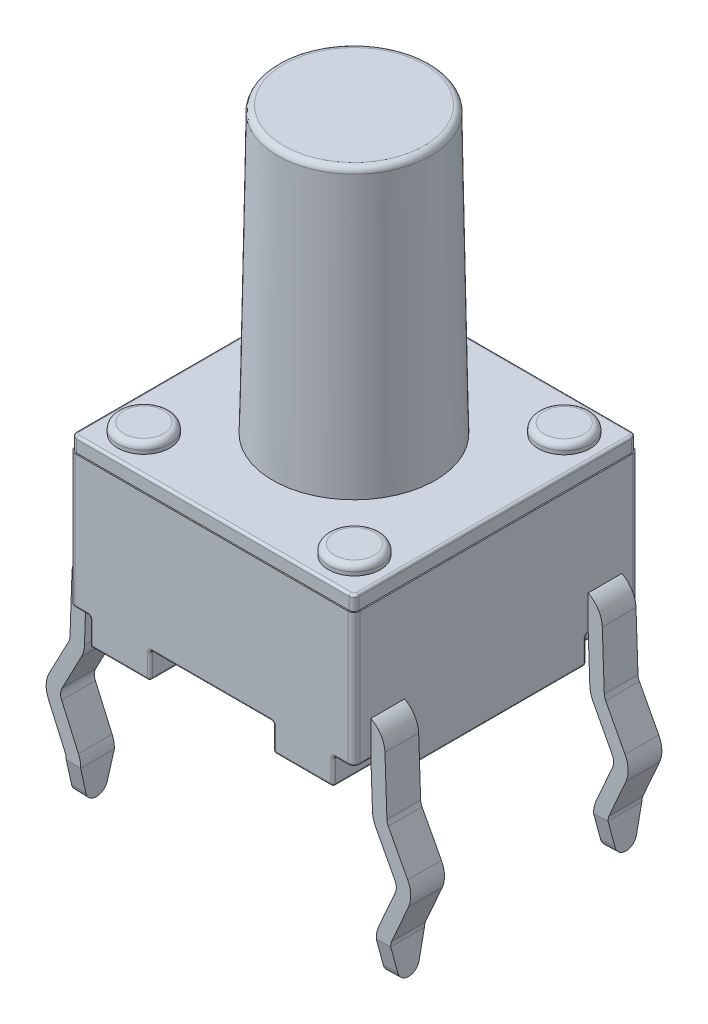
from build123d import *

# Parameters (mm, degrees)
BOSS_EXTRUDE1_START  = 0.5588
SKETCH1_W            = 6.0071
SKETCH1_H            = 6.0071
BOSS_EXTRUDE1_DEPTH  = 2.8194
FILLET1_R            = 0.127
BOSS_EXTRUDE2_DEPTH  = 0.3048
BOSS_EXTRUDE3_REACH  = 7.622
SKETCH4_R            = 0.5461
BOSS_EXTRUDE4_DEPTH  = 0.2032
SKETCH5_R            = 1.7145
BOSS_EXTRUDE5_DEPTH  = 6
BOSS_EXTRUDE5_TAPER  = 1
FILLET2_R            = 0.127
FILLET3_R            = 0.0508
EXTRUDE_THIN1_START  = -0.3556
EXTRUDE_THIN1_DEPTH  = 0.7112
CUT_EXTRUDE1_DEPTH   = 0.7112
MIRROR3_START        = -0.3556
MIRROR3_COPY_1_DEPTH = 0.7112
MIRROR3_COPY_2_DEPTH = 0.7112


with BuildPart() as part:
    # Sketch1 → Boss-Extrude1 (new body)
    with BuildSketch(Plane(origin=(0, 0, 0), x_dir=(1, 0, 0), z_dir=(0, 1, 0)).offset(BOSS_EXTRUDE1_START)):
        Rectangle(SKETCH1_W, SKETCH1_H)
    extrude(amount=BOSS_EXTRUDE1_DEPTH)

    # Fillet1
    fillet1_edges = [part.edges().sort_by_distance(p)[0] for p in [
        (3.00355, 1.9685, 3.00355),
        (-3.00355, 1.9685, 3.00355),
        (-3.00355, 1.9685, -3.00355),
        (3.00355, 1.9685, -3.00355),
    ]]
    fillet(fillet1_edges, radius=FILLET1_R)

    # Sketch2 → Boss-Extrude2 (add)
    with BuildSketch(Plane(origin=(0, 3.3782, 0), x_dir=(-1, 0, 0), z_dir=(0, -1, 0))):
        with BuildLine():
            Line((2.97815, -2.87655), (2.97815, 2.87655))
            ThreePointArc((2.97815, 2.87655), (2.948392049, 2.948392049), (2.87655, 2.97815))
            Line((2.87655, 2.97815), (-2.87655, 2.97815))
            ThreePointArc((-2.87655, 2.97815), (-2.948392049, 2.948392049), (-2.97815, 2.87655))
            Line((-2.97815, 2.87655), (-2.97815, -2.87655))
            ThreePointArc((-2.97815, -2.87655), (-2.948392049, -2.948392049), (-2.87655, -2.97815))
            Line((-2.87655, -2.97815), (2.87655, -2.97815))
            ThreePointArc((2.87655, -2.97815), (2.948392049, -2.948392049), (2.97815, -2.87655))
        make_face()
    extrude(amount=-BOSS_EXTRUDE2_DEPTH)

    # Sketch3 → Boss-Extrude3 (add, up to next)
    with BuildSketch(Plane(origin=(0, 0, 0), x_dir=(1, 0, 0), z_dir=(0, 1, 0)), mode=Mode.PRIVATE) as boss_extrude3_sk1:
        Polygon((-2.566197678, -3.00355), (-2.566197678, -1.89483443), (-3.00355, -1.89483443), (-3.00355, 1.89483443), (-2.566197678, 1.89483443), (-2.566197678, 3.00355), (-1.30175, 3.00355), (-1.30175, 0.560941661), (-2.441300776, 0.560941661), (-2.441300776, -0.560941661), (-1.30175, -0.560941661), (-1.30175, -3.00355), align=None)
    boss_extrude3_tool1 = extrude(boss_extrude3_sk1.sketch, amount=BOSS_EXTRUDE3_REACH, mode=Mode.PRIVATE) - part.part
    # Sketch3 → Boss-Extrude3 (add, up to next)
    with BuildSketch(Plane(origin=(0, 0, 0), x_dir=(1, 0, 0), z_dir=(0, 1, 0)), mode=Mode.PRIVATE) as boss_extrude3_sk2:
        Polygon((2.566197678, 3.00355), (2.566197678, 1.89483443), (3.00355, 1.89483443), (3.00355, -1.89483443), (2.566197678, -1.89483443), (2.566197678, -3.00355), (1.30175, -3.00355), (1.30175, -0.560941661), (2.441300776, -0.560941661), (2.441300776, 0.560941661), (1.30175, 0.560941661), (1.30175, 3.00355), align=None)
    boss_extrude3_tool2 = extrude(boss_extrude3_sk2.sketch, amount=BOSS_EXTRUDE3_REACH, mode=Mode.PRIVATE) - part.part
    add(boss_extrude3_tool1.solids().sort_by_distance((-2.503763, 0, 2.449192))[0])
    add(boss_extrude3_tool2.solids().sort_by_distance((2.503763, 0, -2.449192))[0])

    # Sketch4 → Boss-Extrude4 (add)
    with BuildSketch(Plane(origin=(0, 3.683, 0), x_dir=(1, 0, 0), z_dir=(0, 1, 0))):
        with Locations(Location((2.221694311, 2.212885437, 0), (0, 0, 90))):
            Circle(SKETCH4_R)
        with Locations(Location((-2.221694311, 2.212885437, 0), (0, 0, 90))):
            Circle(SKETCH4_R)
        with Locations(Location((-2.221694311, -2.212885437, 0), (0, 0, 90))):
            Circle(SKETCH4_R)
        with Locations(Location((2.221694311, -2.212885437, 0), (0, 0, 90))):
            Circle(SKETCH4_R)
    extrude(amount=BOSS_EXTRUDE4_DEPTH)

    # Sketch5 → Boss-Extrude5 (add)
    with BuildSketch(Plane(origin=(0, 3.683, 0), x_dir=(1, 0, 0), z_dir=(0, 1, 0))):
        Circle(SKETCH5_R)
    extrude(amount=BOSS_EXTRUDE5_DEPTH, taper=BOSS_EXTRUDE5_TAPER)

    # Fillet2
    fillet2_edges = [part.edges().sort_by_distance(p)[0] for p in [
        (2.221694311, 3.8862, -1.666785437),
        (-2.221694311, 3.8862, -1.666785437),
        (-2.221694311, 3.8862, 2.758985437),
        (2.221694311, 3.8862, 2.758985437),
        (-1.60976961, 9.683, 0),
    ]]
    fillet(fillet2_edges, radius=FILLET2_R)

    # Fillet3
    fillet3_edges = [part.edges().sort_by_distance(p)[0] for p in [
        (1.30175, 0.5588, -1.782245831),
        (1.30175, 0.2794, -3.00355),
        (1.30175, 0, -1.782245831),
        (1.871525388, 0.5588, -0.560941661),
        (1.30175, 0.2794, -0.560941661),
        (1.871525388, 0, -0.560941661),
        (2.441300776, 0.5588, 0),
        (2.441300776, 0.2794, -0.560941661),
        (2.441300776, 0, 0),
        (1.871525388, 0.5588, 0.560941661),
        (2.441300776, 0.2794, 0.560941661),
        (1.871525388, 0, 0.560941661),
        (1.30175, 0.5588, 1.782245831),
        (1.30175, 0.2794, 0.560941661),
        (1.30175, 0, 1.782245831),
        (1.30175, 0.2794, 3.00355),
        (1.933973839, 0, 3.00355),
        (2.566197678, 0.5588, 2.449192215),
        (2.566197678, 0.2794, 3.00355),
        (2.566197678, 0, 2.449192215),
        (2.784873839, 0.5588, 1.89483443),
        (2.566197678, 0.2794, 1.89483443),
        (2.784873839, 0, 1.89483443),
        (3.00355, 0.2794, 1.89483443),
        (3.00355, 0, 0),
        (2.784873839, 0.5588, -1.89483443),
        (3.00355, 0.2794, -1.89483443),
        (2.784873839, 0, -1.89483443),
        (2.566197678, 0.2794, -3.00355),
        (1.933973839, 0, -3.00355),
        (2.566197678, 0.5588, -2.449192215),
        (2.566197678, 0.2794, -1.89483443),
        (2.566197678, 0, -2.449192215),
        (-2.721373839, 0.5588, 3.00355),
        (3.00355, 0.5588, 2.385692215),
        (-3.00355, 0.5588, -2.385692215),
        (2.721373839, 0.5588, -3.00355),
        (2.966352561, 0.5588, 2.966352561),
        (2.966352561, 0.5588, -2.966352561),
        (-2.966352561, 0.5588, -2.966352561),
        (-2.966352561, 0.5588, 2.966352561),
        (-2.948392049, 3.683, 2.948392049),
        (0, 3.683, 2.97815),
        (2.948392049, 3.683, 2.948392049),
        (2.97815, 3.683, 0),
        (2.948392049, 3.683, -2.948392049),
        (0, 3.683, -2.97815),
        (-2.948392049, 3.683, -2.948392049),
        (-2.97815, 3.683, 0),
        (0, 0.5588, 3.00355),
        (-3.00355, 0.5588, 2.385692215),
        (-2.721373839, 0.5588, -3.00355),
        (-1.30175, 0.5588, 1.782245831),
        (-1.30175, 0.2794, 3.00355),
        (-1.30175, 0, 1.782245831),
        (-1.871525388, 0.5588, 0.560941661),
        (-1.30175, 0.2794, 0.560941661),
        (-1.871525388, 0, 0.560941661),
        (-2.441300776, 0.5588, 0),
        (-2.441300776, 0.2794, 0.560941661),
        (-2.441300776, 0, 0),
        (-1.871525388, 0.5588, -0.560941661),
        (-2.441300776, 0.2794, -0.560941661),
        (-1.871525388, 0, -0.560941661),
        (-1.30175, 0.5588, -1.782245831),
        (-1.30175, 0.2794, -0.560941661),
        (-1.30175, 0, -1.782245831),
        (-1.30175, 0.2794, -3.00355),
        (-1.933973839, 0, -3.00355),
        (-2.566197678, 0.5588, -2.449192215),
        (-2.566197678, 0.2794, -3.00355),
        (-2.566197678, 0, -2.449192215),
        (-2.784873839, 0.5588, -1.89483443),
        (-2.566197678, 0.2794, -1.89483443),
        (-2.784873839, 0, -1.89483443),
        (-3.00355, 0.2794, -1.89483443),
        (-3.00355, 0, 0),
        (-2.784873839, 0.5588, 1.89483443),
        (-3.00355, 0.2794, 1.89483443),
        (-2.784873839, 0, 1.89483443),
        (-2.566197678, 0.2794, 3.00355),
        (-1.933973839, 0, 3.00355),
        (-2.566197678, 0.5588, 2.449192215),
        (-2.566197678, 0.2794, 1.89483443),
        (-2.566197678, 0, 2.449192215),
        (0, 0.5588, -3.00355),
        (3.00355, 0.5588, -2.385692215),
        (2.721373839, 0.5588, 3.00355),
    ]]
    fillet(fillet3_edges, radius=FILLET3_R)

    # Sketch6 → Extrude-Thin1 (add)
    with BuildSketch(Plane.XY.offset(3.00355).offset(EXTRUDE_THIN1_START)):
        with BuildLine():
            Line((-2.526489479, 1.064092226), (-2.74199854, 1.064092226))
            ThreePointArc((-2.74199854, 1.064092226), (-2.918441767, 0.992804535), (-2.995843811, 0.818956698))
            Line((-2.995843811, 0.818956698), (-3.03780929, -0.382777412))
            ThreePointArc((-3.03780929, -0.382777412), (-3.056264298, -0.506985303), (-3.10198813, -0.623936226))
            Line((-3.10198813, -0.623936226), (-3.511410555, -1.400308198))
            ThreePointArc((-3.511410555, -1.400308198), (-3.540582755, -1.509925841), (-3.519128157, -1.62131141))
            Line((-3.519128157, -1.62131141), (-3.164860036, -2.424352043))
            ThreePointArc((-3.164860036, -2.424352043), (-3.127405669, -2.544207613), (-3.117659921, -2.669400296))
            Line((-3.117659921, -2.669400296), (-3.142411752, -3.3782))
            Line((-3.142411752, -3.3782), (-3.447026076, -3.367562633))
            Line((-3.447026076, -3.367562633), (-3.422274245, -2.658762929))
            ThreePointArc((-3.422274245, -2.658762929), (-3.42670413, -2.601857165), (-3.443728843, -2.54737736))
            Line((-3.443728843, -2.54737736), (-3.797996964, -1.744336727))
            ThreePointArc((-3.797996964, -1.744336727), (-3.845197079, -1.499288474), (-3.781018239, -1.25812966))
            Line((-3.781018239, -1.25812966), (-3.371595814, -0.481757688))
            ThreePointArc((-3.371595814, -0.481757688), (-3.350812254, -0.428598178), (-3.342423614, -0.372140046))
            Line((-3.342423614, -0.372140046), (-3.300458135, 0.829594065))
            ThreePointArc((-3.300458135, 0.829594065), (-3.130173638, 1.212059307), (-2.74199854, 1.368892226))
            Line((-2.74199854, 1.368892226), (-2.526489479, 1.368892226))
            Line((-2.526489479, 1.368892226), (-2.526489479, 1.064092226))
        make_face()
    extrude_thin1 = extrude(amount=-EXTRUDE_THIN1_DEPTH)

    # Sketch9 → Cut-Extrude1 (cut)
    with BuildSketch(Plane(origin=(-3.325373038, 0.116124585, 0), x_dir=(0, 0, 1), z_dir=(-0.9993908270190957, 0.03489949670250484, 0))):
        with BuildLine():
            Line((2.64795, -3.48581068), (2.64795, -2.776578932))
            Line((2.64795, -2.776578932), (2.517535772, -3.30911696))
            ThreePointArc((2.517535772, -3.30911696), (2.435466476, -3.436364343), (2.29235, -3.48581068))
            Line((2.29235, -3.48581068), (2.64795, -3.48581068))
        make_face()
        with BuildLine():
            Line((1.93675, -3.48581068), (2.29235, -3.48581068))
            ThreePointArc((2.29235, -3.48581068), (2.149233524, -3.436364343), (2.067164228, -3.30911696))
            Line((2.067164228, -3.30911696), (1.93675, -2.776578932))
            Line((1.93675, -2.776578932), (1.93675, -3.48581068))
        make_face()
    cut_extrude1 = extrude(amount=-CUT_EXTRUDE1_DEPTH, mode=Mode.SUBTRACT)

    # Mirror1: Extrude-Thin1, Cut-Extrude1 across plane
    add(extrude_thin1.mirror(Plane.XY))
    add(cut_extrude1.mirror(Plane.XY), mode=Mode.SUBTRACT)

    # Mirror3: Extrude-Thin1, Cut-Extrude1 across plane
    add(extrude_thin1.mirror(Plane(origin=(0, 0, 0), x_dir=(0, 0, 1), z_dir=(1, 0, 0))))
    add(cut_extrude1.mirror(Plane(origin=(0, 0, 0), x_dir=(0, 0, 1), z_dir=(1, 0, 0))), mode=Mode.SUBTRACT)

    # Mirror3 copy 1 sketch → Mirror3 copy 1 (add)
    with BuildSketch(Plane(origin=(0, 0, -3.00355), x_dir=(-1, 0, 0), z_dir=(0, 0, -1)).offset(MIRROR3_START)):
        with BuildLine():
            Line((-2.526489479, 1.064092226), (-2.74199854, 1.064092226))
            ThreePointArc((-2.74199854, 1.064092226), (-2.918441767, 0.992804535), (-2.995843811, 0.818956698))
            Line((-2.995843811, 0.818956698), (-3.03780929, -0.382777412))
            ThreePointArc((-3.03780929, -0.382777412), (-3.056264298, -0.506985303), (-3.10198813, -0.623936226))
            Line((-3.10198813, -0.623936226), (-3.511410555, -1.400308198))
            ThreePointArc((-3.511410555, -1.400308198), (-3.540582755, -1.509925841), (-3.519128157, -1.62131141))
            Line((-3.519128157, -1.62131141), (-3.164860036, -2.424352043))
            ThreePointArc((-3.164860036, -2.424352043), (-3.127405669, -2.544207613), (-3.117659921, -2.669400296))
            Line((-3.117659921, -2.669400296), (-3.142411752, -3.3782))
            Line((-3.142411752, -3.3782), (-3.447026076, -3.367562633))
            Line((-3.447026076, -3.367562633), (-3.422274245, -2.658762929))
            ThreePointArc((-3.422274245, -2.658762929), (-3.42670413, -2.601857165), (-3.443728843, -2.54737736))
            Line((-3.443728843, -2.54737736), (-3.797996964, -1.744336727))
            ThreePointArc((-3.797996964, -1.744336727), (-3.845197079, -1.499288474), (-3.781018239, -1.25812966))
            Line((-3.781018239, -1.25812966), (-3.371595814, -0.481757688))
            ThreePointArc((-3.371595814, -0.481757688), (-3.350812254, -0.428598178), (-3.342423614, -0.372140046))
            Line((-3.342423614, -0.372140046), (-3.300458135, 0.829594065))
            ThreePointArc((-3.300458135, 0.829594065), (-3.130173638, 1.212059307), (-2.74199854, 1.368892226))
            Line((-2.74199854, 1.368892226), (-2.526489479, 1.368892226))
            Line((-2.526489479, 1.368892226), (-2.526489479, 1.064092226))
        make_face()
    extrude(amount=-MIRROR3_COPY_1_DEPTH)

    # Mirror3 copy 2 sketch → Mirror3 copy 2 (cut)
    with BuildSketch(Plane(origin=(3.325373038, 0.116124585, 0), x_dir=(0, 0, -1), z_dir=(0.9993908270190957, 0.03489949670250484, 0))):
        with BuildLine():
            Line((2.64795, -3.48581068), (2.64795, -2.776578932))
            Line((2.64795, -2.776578932), (2.517535772, -3.30911696))
            ThreePointArc((2.517535772, -3.30911696), (2.435466476, -3.436364343), (2.29235, -3.48581068))
            Line((2.29235, -3.48581068), (2.64795, -3.48581068))
        make_face()
        with BuildLine():
            Line((1.93675, -3.48581068), (2.29235, -3.48581068))
            ThreePointArc((2.29235, -3.48581068), (2.149233524, -3.436364343), (2.067164228, -3.30911696))
            Line((2.067164228, -3.30911696), (1.93675, -2.776578932))
            Line((1.93675, -2.776578932), (1.93675, -3.48581068))
        make_face()
    extrude(amount=-MIRROR3_COPY_2_DEPTH, mode=Mode.SUBTRACT)


solid = part.part
